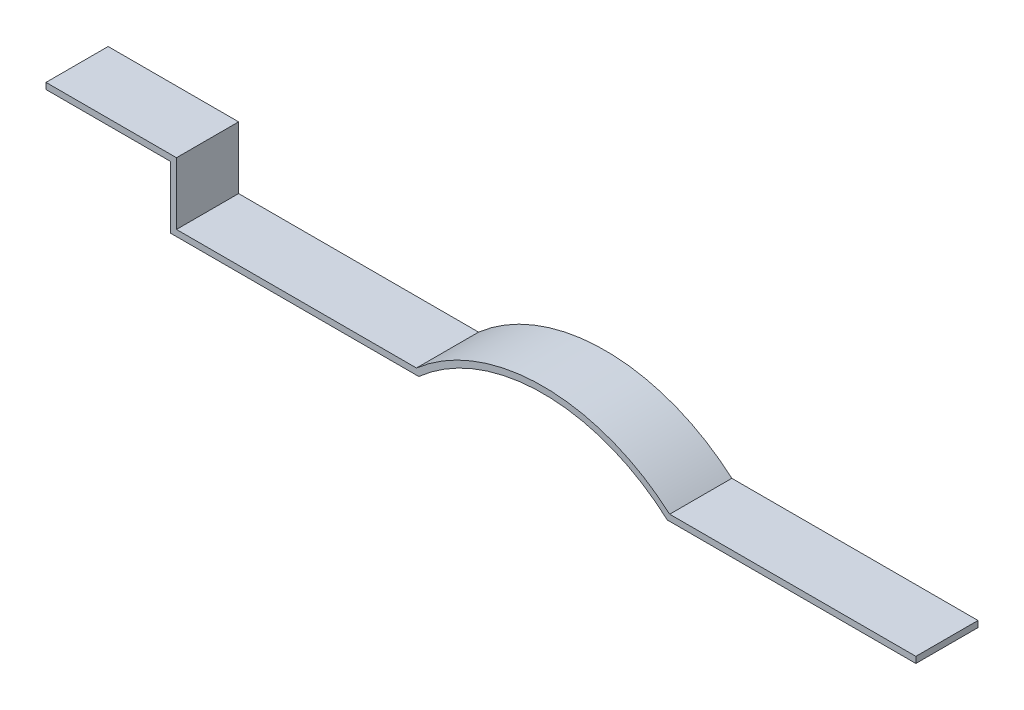
from build123d import *

# Parameters (mm, degrees)
BOSS_EXTRUDE1_DEPTH = 50


with BuildPart() as part:
    # Sketch1 → Boss-Extrude1 (new body)
    with BuildSketch(Plane.XY):
        with BuildLine():
            Line((0, 0), (-200, 0))
            ThreePointArc((-200, 0), (-300, 38.196601125), (-400, 0))
            Line((-400, 0), (-600, 0))
            Line((-600, 0), (-600, 50))
            Line((-600, 50), (-700, 50))
            Line((-700, 50), (-700, 55))
            Line((-700, 55), (-595, 55))
            Line((-595, 55), (-595, 5))
            Line((-595, 5), (-401.891933004, 5))
            ThreePointArc((-401.891933004, 5), (-300, 43.196601125), (-198.108066996, 5))
            Line((-198.108066996, 5), (0, 5))
            Line((0, 5), (0, 0))
        make_face()
    extrude(amount=BOSS_EXTRUDE1_DEPTH)


solid = part.part
